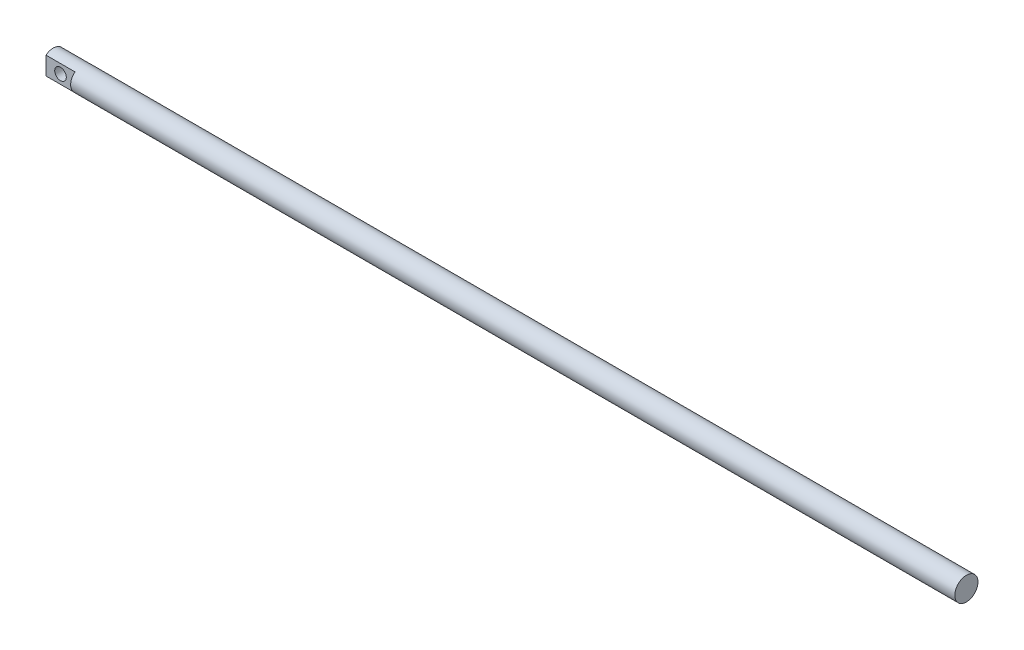
from build123d import *

# Parameters (mm, degrees)
SKETCH_1_R           = 8
EXTRUDE_1_DEPTH      = 630
SKETCH_3_OUTSIDE_W   = 144.082
SKETCH_3_OUTSIDE_H   = 144.082
SKETCH_3_OUTSIDE_W_2 = 10
SKETCH_3_OUTSIDE_H_2 = 20
CUT_EXTRUDE_1_DEPTH  = 20
SKETCH_4_R           = 4
CUT_EXTRUDE_3_DEPTH  = 20


with BuildPart() as part:
    # 草图1 → 凸台-拉伸1 (new body)
    with BuildSketch(Plane(origin=(0, 0, 0), x_dir=(0, 0, -1), z_dir=(1, 0, 0))):
        Circle(SKETCH_1_R)
    extrude(amount=EXTRUDE_1_DEPTH)

    # 草图3 outside → 切除-拉伸1 (cut)
    with BuildSketch(Plane.ZY):
        Rectangle(SKETCH_3_OUTSIDE_W, SKETCH_3_OUTSIDE_H)
        Rectangle(SKETCH_3_OUTSIDE_W_2, SKETCH_3_OUTSIDE_H_2, mode=Mode.SUBTRACT)
    extrude(amount=-CUT_EXTRUDE_1_DEPTH, mode=Mode.SUBTRACT)

    # 草图4 → 切除-拉伸3 (cut)
    with BuildSketch(Plane(origin=(0, 0, -5), x_dir=(-1, 0, 0), z_dir=(0, 0, -1))):
        with Locations((-10, 0)):
            Circle(SKETCH_4_R)
    extrude(amount=-CUT_EXTRUDE_3_DEPTH, mode=Mode.SUBTRACT)


solid = part.part
